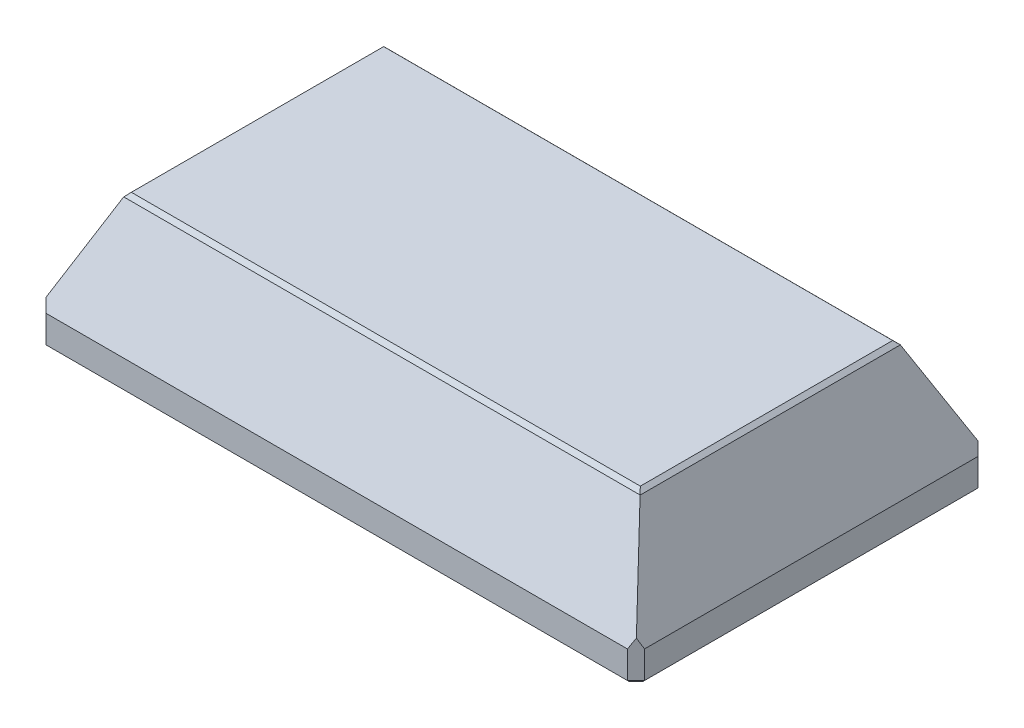
from build123d import *
from OCP.BRepFilletAPI import BRepFilletAPI_MakeChamfer

# Parameters (mm, degrees)
SKETCH1_W                       = 140
SKETCH1_H                       = 82
BOSS_EXTRUDE1_DEPTH             = 7
SKETCH3_W                       = 140
SKETCH3_H                       = 82
SKETCH2_W                       = 120
SKETCH2_H                       = 60
CHAMFER1_SIZE                   = 2
SKETCH4_R                       = 2.05
CUT_EXTRUDE1_DEPTH              = 7
SKETCH5_W                       = 114
SKETCH5_H                       = 50
CUT_EXTRUDE2_DEPTH              = 29
SKETCH6_W                       = 114
SKETCH6_H                       = 62
CUT_EXTRUDE3_DEPTH              = 25
SKETCH7_W                       = 6
SKETCH7_H                       = 62
CUT_EXTRUDE4_DEPTH              = 4
SKETCH8_R                       = 2.05
CUT_EXTRUDE5_DEPTH              = 6
CHAMFER2_SIZE                   = 1
CHAMFER2_SIZE2                  = 0.471497246
CHAMFER2_SIZE2_2                = 0.488486876
CHAMFER3_SIZE                   = 0.6
SKIZZE1_W                       = 54.050484576
SKIZZE1_H                       = 7.5
SKIZZE1_W_2                     = 4
SKIZZE1_H_2                     = 21.453027382
AUFSATZ_LINEAR_AUSTRAGEN1_DEPTH = 10
SKIZZE3_W                       = 29.974757712
SKIZZE3_H                       = 3
SCHNITT_LINEAR_AUSTRAGEN2_DEPTH = 4


with BuildPart() as part:
    # Sketch1 → Boss-Extrude1 (new body)
    with BuildSketch(Plane(origin=(0, 0, 0), x_dir=(1, 0, 0), z_dir=(0, 1, 0))):
        Rectangle(SKETCH1_W, SKETCH1_H)
    extrude(amount=BOSS_EXTRUDE1_DEPTH)

    # Sketch3 → Loft2 section 0
    with BuildSketch(Plane(origin=(0, 7, 0), x_dir=(1, 0, 0), z_dir=(0, 1, 0))):
        Rectangle(SKETCH3_W, SKETCH3_H)
    # Sketch2 → Loft2 section 1
    with BuildSketch(Plane(origin=(0, 30, 0), x_dir=(1, 0, 0), z_dir=(0, 1, 0))):
        Rectangle(SKETCH2_W, SKETCH2_H)
    loft()

    # Chamfer1
    chamfer1_edges = [part.edges().sort_by_distance(p)[0] for p in [
        (-70, 3.5, 41),
        (70, 3.5, 41),
        (70, 3.5, -41),
        (-70, 3.5, -41),
    ]]
    chamfer(chamfer1_edges, length=CHAMFER1_SIZE)

    # Sketch4 → Cut-Extrude1 (cut)
    with BuildSketch(Plane.XZ):
        with Locations(Location((40, -37.5, 0), (0, 0, 270))):
            Circle(SKETCH4_R)
        with Locations(Location((-40, -37.5, 0), (0, 0, 270))):
            Circle(SKETCH4_R)
    cut_extrude1 = extrude(amount=-CUT_EXTRUDE1_DEPTH, mode=Mode.SUBTRACT)

    # Sketch5 → Cut-Extrude2 (cut)
    with BuildSketch(Plane.XZ):
        Rectangle(SKETCH5_W, SKETCH5_H)
    extrude(amount=-CUT_EXTRUDE2_DEPTH, mode=Mode.SUBTRACT)

    # Mirror1: Cut-Extrude1 across plane
    add(cut_extrude1.mirror(Plane.XY), mode=Mode.SUBTRACT)

    # Sketch6 → Cut-Extrude3 (cut)
    with BuildSketch(Plane.XZ):
        Rectangle(SKETCH6_W, SKETCH6_H)
    extrude(amount=-CUT_EXTRUDE3_DEPTH, mode=Mode.SUBTRACT)

    # Sketch7 → Cut-Extrude4 (cut)
    with BuildSketch(Plane.XZ):
        with Locations((-60, 0)):
            Rectangle(SKETCH7_W, SKETCH7_H)
        with Locations((60, 0)):
            Rectangle(SKETCH7_W, SKETCH7_H)
    extrude(amount=-CUT_EXTRUDE4_DEPTH, mode=Mode.SUBTRACT)

    # Sketch8 → Cut-Extrude5 (cut)
    with BuildSketch(Plane.XZ.offset(-4)):
        with Locations(Location((-60, 25, 0), (0, 0, 270))):
            Circle(SKETCH8_R)
        with Locations(Location((-60, -25, 0), (0, 0, 270))):
            Circle(SKETCH8_R)
        with Locations(Location((60, -25, 0), (0, 0, 90))):
            Circle(SKETCH8_R)
        with Locations(Location((60, 25, 0), (0, 0, 90))):
            Circle(SKETCH8_R)
    extrude(amount=-CUT_EXTRUDE5_DEPTH, mode=Mode.SUBTRACT)

    # Chamfer2: one chamfer whose edges measure the first distance from different faces: ONE call of the kernel's chamfer builder (chamfer() names one face for all edges)
    chamfer2_edges_1 = [part.edges().sort_by_distance(p)[0] for p in [
        (60, 30, 0),
    ]]
    chamfer2_side_1 = [part.faces().sort_by_distance(p)[0] for p in [
        (65.246314621, 17.933476372, 0),
    ]]
    chamfer2_edges_2 = [part.edges().sort_by_distance(p)[0] for p in [
        (0, 30, -30),
    ]]
    chamfer2_side_2 = [part.faces().sort_by_distance(p)[0] for p in [
        (0, 18.220498667, -35.633674551),
    ]]
    chamfer2_edges_3 = [part.edges().sort_by_distance(p)[0] for p in [
        (-60, 30, 0),
    ]]
    chamfer2_side_3 = [part.faces().sort_by_distance(p)[0] for p in [
        (-65.246314621, 17.933476372, 0),
    ]]
    chamfer2_edges_4 = [part.edges().sort_by_distance(p)[0] for p in [
        (0, 30, 30),
    ]]
    chamfer2_side_4 = [part.faces().sort_by_distance(p)[0] for p in [
        (0, 18.220498667, 35.633674551),
    ]]
    chamfer2 = BRepFilletAPI_MakeChamfer(part.part.solid().wrapped)
    for e in chamfer2_edges_1:
        chamfer2.Add(CHAMFER2_SIZE, CHAMFER2_SIZE2, e.wrapped, chamfer2_side_1[0].wrapped)  # the first distance lies on this face
    for e in chamfer2_edges_2:
        chamfer2.Add(CHAMFER2_SIZE, CHAMFER2_SIZE2_2, e.wrapped, chamfer2_side_2[0].wrapped)  # the first distance lies on this face
    for e in chamfer2_edges_3:
        chamfer2.Add(CHAMFER2_SIZE, CHAMFER2_SIZE2, e.wrapped, chamfer2_side_3[0].wrapped)  # the first distance lies on this face
    for e in chamfer2_edges_4:
        chamfer2.Add(CHAMFER2_SIZE, CHAMFER2_SIZE2_2, e.wrapped, chamfer2_side_4[0].wrapped)  # the first distance lies on this face
    add(Compound.cast(chamfer2.Shape()), mode=Mode.REPLACE)

    # Chamfer3
    chamfer3_edges = [part.edges().sort_by_distance(p)[0] for p in [
        (0, 0, 41),
        (70, 0, 0),
        (-70, 0, 0),
        (0, 0, -41),
        (-69, 0, -40),
        (69, 0, -40),
        (69, 0, 40),
        (-69, 0, 40),
    ]]
    chamfer(chamfer3_edges, length=CHAMFER3_SIZE)

    # Skizze1 → Aufsatz-Linear austragen1 (add)
    with BuildSketch(Plane.XZ.offset(-29)):
        with Locations((0, -21.25)):
            Rectangle(SKIZZE1_W, SKIZZE1_H)
        with Locations((0, 21.25)):
            Rectangle(SKIZZE1_W, SKIZZE1_H)
        with Locations((55, 0)):
            Rectangle(SKIZZE1_W_2, SKIZZE1_H_2)
    extrude(amount=AUFSATZ_LINEAR_AUSTRAGEN1_DEPTH)

    # Skizze3 → Schnitt-Linear austragen2 (cut)
    with BuildSketch(Plane(origin=(0, 29, 0), x_dir=(-1, 0, 0), z_dir=(0, -1, 0))):
        with Locations((42.012621144, -26.5)):
            Rectangle(SKIZZE3_W, SKIZZE3_H)
        with Locations((-42.012621144, -26.5)):
            Rectangle(SKIZZE3_W, SKIZZE3_H)
        with Locations((42.012621144, 26.5)):
            Rectangle(SKIZZE3_W, SKIZZE3_H)
        with Locations((-42.012621144, 26.5)):
            Rectangle(SKIZZE3_W, SKIZZE3_H)
    extrude(amount=SCHNITT_LINEAR_AUSTRAGEN2_DEPTH, mode=Mode.SUBTRACT)


solid = part.part
